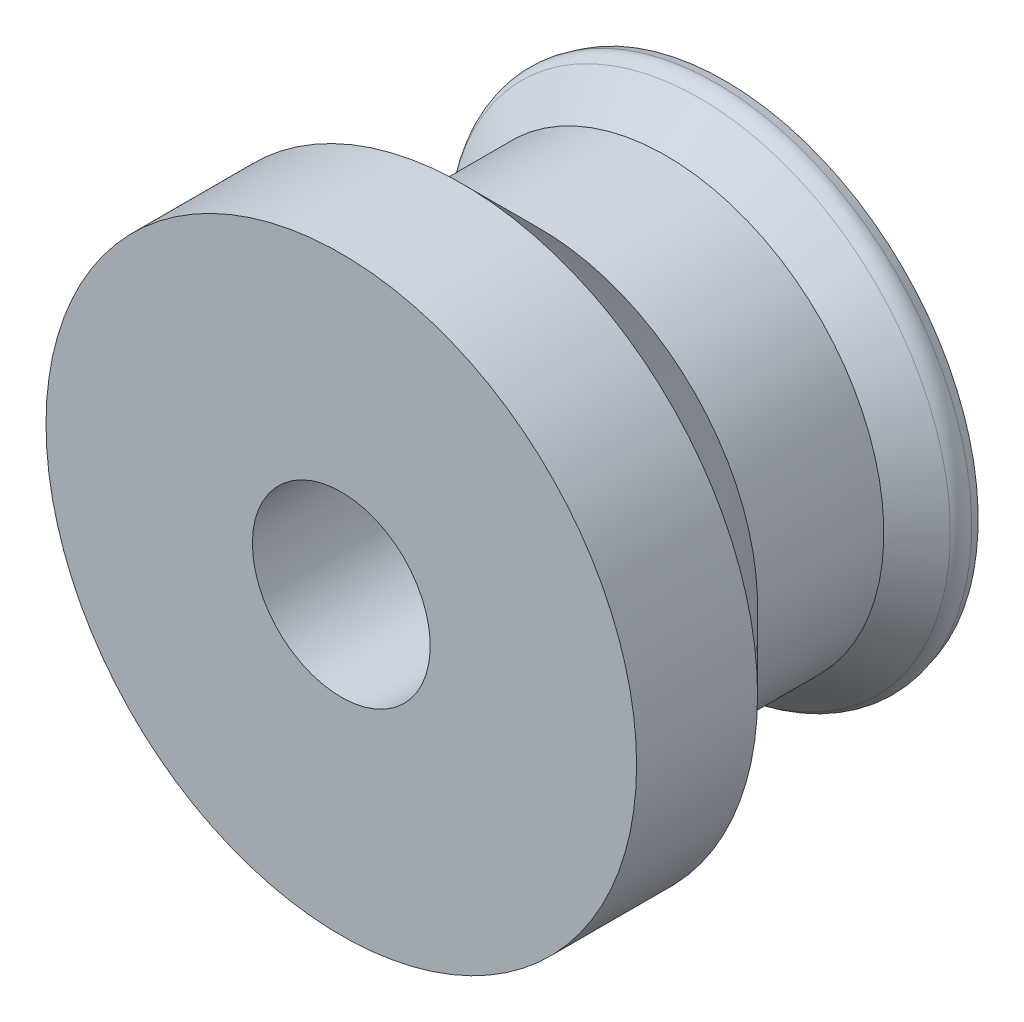
from build123d import *

# Parameters (mm, degrees)
F_5_1_5_1_DIAMETER_HOLE1_D = 5.1


with BuildPart() as part:
    # Sketch1 → Revolve1 (revolve)
    with BuildSketch(Plane.XZ.offset(64.320770854)):
        with BuildLine():
            Line((114.770297578, 11), (106.300627664, 11))
            Line((106.300627664, 11), (106.300627664, 0))
            Line((106.300627664, 0), (113.567535888, 0))
            Line((113.567535888, 0), (113.634922783, 0.251491318))
            ThreePointArc((113.634922783, 0.251491318), (113.634922783, 0.510310363), (113.505513261, 0.734454231))
            Line((113.505513261, 0.734454231), (112.550627664, 1.689339828))
            Line((112.550627664, 1.689339828), (112.550627664, 5.310660172))
            Line((112.550627664, 5.310660172), (114.770297578, 7.530330086))
            Line((114.770297578, 7.530330086), (114.770297578, 11))
        make_face()
    revolve(axis=Axis((106.300627664, -64.320770854, 11), (0, 0, -1)))

    # Ø5.1 (5.1) Diameter Hole1 (through all)
    with Locations(Plane(origin=(0, 0, 0), x_dir=(-1, 0, 0), z_dir=(0, 0, -1))):
        with Locations((-106.300627664, -64.320770854)):
            Hole(F_5_1_5_1_DIAMETER_HOLE1_D / 2)


solid = part.part
